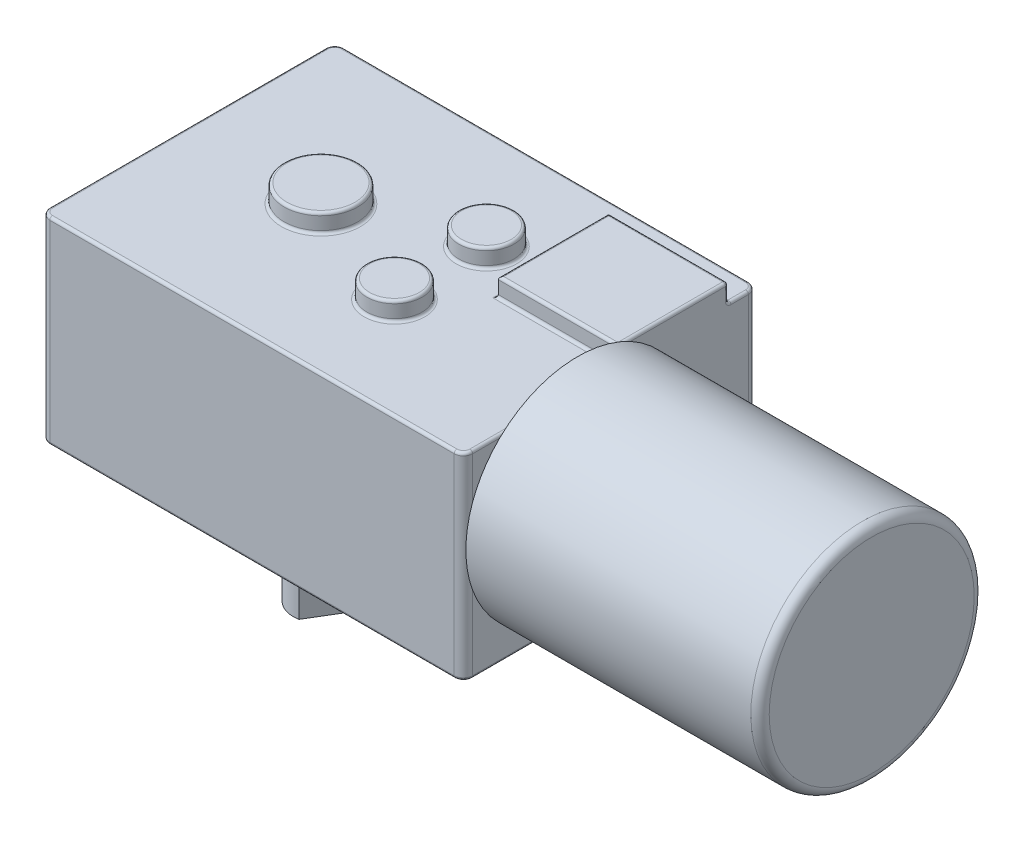
from build123d import *

# Parameters (mm, degrees)
SKETCH1_W           = 46
SKETCH1_H           = 32
BOSS_EXTRUDE1_DEPTH = 21.5
FILLET1_R           = 1
SKETCH2_W           = 13
SKETCH2_H           = 12
BOSS_EXTRUDE2_DEPTH = 2
SKETCH3_R           = 4
SKETCH3_R_2         = 3
BOSS_EXTRUDE3_DEPTH = 2
SKETCH4_R           = 6.75
SKETCH4_R_2         = 4
SKETCH4_R_3         = 1.5
SKETCH4_R_4         = 3
BOSS_EXTRUDE4_DEPTH = 2
FILLET2_R           = 0.3
SKETCH5_R           = 12.15
BOSS_EXTRUDE5_DEPTH = 32
FILLET3_R           = 1
SKETCH6_R           = 5
CUT_EXTRUDE1_DEPTH  = 0.1
SKETCH7_R           = 3
BOSS_EXTRUDE6_DEPTH = 14
CUT_EXTRUDE2_DEPTH  = 11


with BuildPart() as part:
    # Sketch1 → Boss-Extrude1 (new body)
    with BuildSketch(Plane(origin=(0, 0, 0), x_dir=(1, 0, 0), z_dir=(0, 1, 0))):
        Rectangle(SKETCH1_W, SKETCH1_H)
    extrude(amount=BOSS_EXTRUDE1_DEPTH)

    # Fillet1
    fillet1_edges = [part.edges().sort_by_distance(p)[0] for p in [
        (23, 10.75, 16),
        (-23, 10.75, 16),
        (-23, 10.75, -16),
        (23, 10.75, -16),
    ]]
    fillet(fillet1_edges, radius=FILLET1_R)

    # Sketch2 → Boss-Extrude2 (add)
    with BuildSketch(Plane(origin=(0, 21.5, 0), x_dir=(1, 0, 0), z_dir=(0, 1, 0))):
        with Locations((16.5, 6.8)):
            Rectangle(SKETCH2_W, SKETCH2_H)
    extrude(amount=BOSS_EXTRUDE2_DEPTH)

    # Sketch3 → Boss-Extrude3 (add)
    with BuildSketch(Plane(origin=(0, 21.5, 0), x_dir=(1, 0, 0), z_dir=(0, 1, 0))):
        with Locations((-8.5, 0)):
            Circle(SKETCH3_R)
        with Locations((4.5, 5)):
            Circle(SKETCH3_R_2)
        with Locations((4.5, -5)):
            Circle(SKETCH3_R_2)
    extrude(amount=BOSS_EXTRUDE3_DEPTH)

    # Sketch4 → Boss-Extrude4 (add)
    with BuildSketch(Plane.XZ):
        with Locations((-8.5, 0)):
            Circle(SKETCH4_R)
        with Locations((-16.4, 9.4)):
            Circle(SKETCH4_R_2)
        with Locations((-16.4, 9.4)):
            Circle(SKETCH4_R_3, mode=Mode.SUBTRACT)
        with Locations((-16.4, -9.4)):
            Circle(SKETCH4_R_2)
        with Locations((-16.4, -9.4)):
            Circle(SKETCH4_R_3, mode=Mode.SUBTRACT)
        with Locations((16.4, -9.4)):
            Circle(SKETCH4_R_2)
        with Locations((16.4, -9.4)):
            Circle(SKETCH4_R_3, mode=Mode.SUBTRACT)
        with Locations((16.4, 9.4)):
            Circle(SKETCH4_R_2)
        with Locations((16.4, 9.4)):
            Circle(SKETCH4_R_3, mode=Mode.SUBTRACT)
        with Locations((4.5, 5)):
            Circle(SKETCH4_R_4)
        with Locations((4.5, -5)):
            Circle(SKETCH4_R_4)
    extrude(amount=BOSS_EXTRUDE4_DEPTH)

    # Fillet2
    fillet2_edges = [part.edges().sort_by_distance(p)[0] for p in [
        (1.5, 0, -5),
        (1.5, -2, -5),
        (-23, 0, 0),
        (-23, 21.5, 0),
        (23, 0, 0),
        (0, 0, 16),
        (0, 0, -16),
        (22.707106781, 0, 15.707106781),
        (22.707106781, 0, -15.707106781),
        (-22.707106781, 0, 15.707106781),
        (-22.707106781, 0, -15.707106781),
        (0, 21.5, -16),
        (23, 21.5, 7.1),
        (0, 21.5, 16),
        (22.707106781, 21.5, 15.707106781),
        (22.707106781, 21.5, -15.707106781),
        (-22.707106781, 21.5, 15.707106781),
        (-22.707106781, 21.5, -15.707106781),
        (23, 21.5, -13.9),
        (23, 22.5, -0.8),
        (16.5, 21.5, -12.8),
        (23, 22.5, -12.8),
        (10, 21.5, -6.8),
        (16.5, 21.5, -0.8),
        (23, 23.5, -6.8),
        (16.5, 23.5, -12.8),
        (10, 23.5, -6.8),
        (16.5, 23.5, -0.8),
        (-12.5, 21.5, 0),
        (-12.5, 23.5, 0),
        (1.5, 21.5, -5),
        (1.5, 23.5, -5),
        (1.5, 21.5, 5),
        (1.5, 23.5, 5),
        (-15.25, 0, 0),
        (-20.4, 0, 9.4),
        (-20.4, -2, 9.4),
        (-17.9, -2, 9.4),
        (-20.4, 0, -9.4),
        (-20.4, -2, -9.4),
        (-17.9, -2, -9.4),
        (12.4, 0, -9.4),
        (12.4, -2, -9.4),
        (14.9, -2, -9.4),
        (12.4, 0, 9.4),
        (12.4, -2, 9.4),
        (14.9, -2, 9.4),
        (1.5, 0, 5),
        (1.5, -2, 5),
    ]]
    fillet(fillet2_edges, radius=FILLET2_R)

    # Sketch5 → Boss-Extrude5 (add)
    with BuildSketch(Plane(origin=(23, 0, 0), x_dir=(0, 0, -1), z_dir=(1, 0, 0))):
        with Locations((-3.584049663, 12.5)):
            Circle(SKETCH5_R)
    extrude(amount=BOSS_EXTRUDE5_DEPTH)

    # Fillet3
    fillet3_edges = [part.edges().sort_by_distance(p)[0] for p in [
        (55, 12.5, 15.734049663),
    ]]
    fillet(fillet3_edges, radius=FILLET3_R)

    # Sketch6 → Cut-Extrude1 (cut)
    with BuildSketch(Plane(origin=(0, -2, 0), x_dir=(1, 0, 0), z_dir=(0, 1, 0))):
        with Locations((-8.5, 0)):
            Circle(SKETCH6_R)
    extrude(amount=CUT_EXTRUDE1_DEPTH, mode=Mode.SUBTRACT)

    # Sketch7 → Boss-Extrude6 (add)
    with BuildSketch(Plane.XZ.offset(1.9)):
        with Locations((-8.5, 0)):
            Circle(SKETCH7_R)
    extrude(amount=BOSS_EXTRUDE6_DEPTH)

    # Sketch8 → Cut-Extrude2 (cut)
    with BuildSketch(Plane.XZ.offset(15.9)):
        Polygon((-7.939226328, 2.947122815), (-5.633433984, -0.884759447), (-2.324296826, 1.10647687), (-4.630089169, 4.938359132), align=None)
    extrude(amount=-CUT_EXTRUDE2_DEPTH, mode=Mode.SUBTRACT)


solid = part.part
